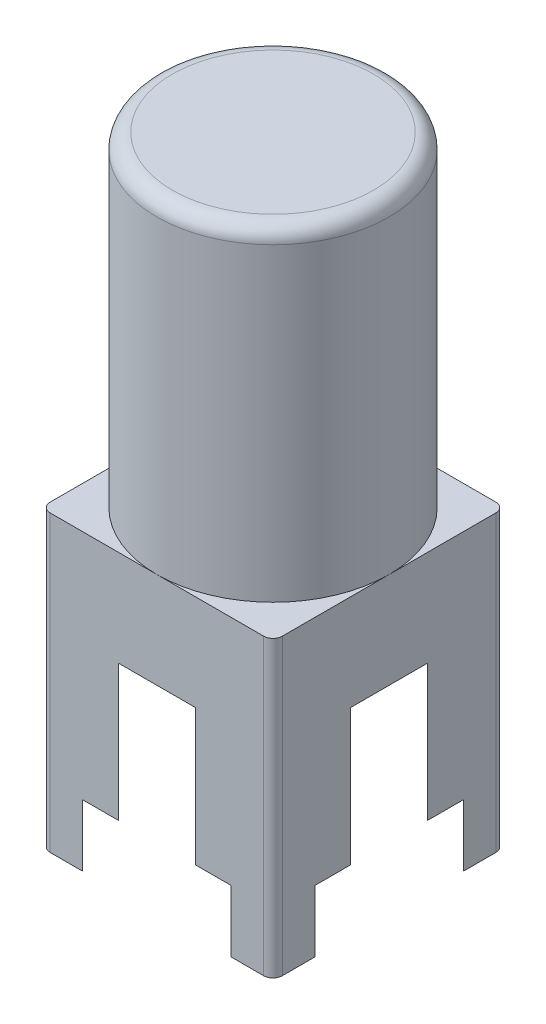
from build123d import *

# Parameters (mm, degrees)
SKETCH1_W           = 9.525
SKETCH1_H           = 9.525
BOSS_EXTRUDE1_DEPTH = 12.065
SKETCH2_R           = 4.7625
BOSS_EXTRUDE2_DEPTH = 13.335
FILLET1_R           = 0.635
SKETCH3_R           = 5.6515
CUT_EXTRUDE1_DEPTH  = 2.54
SKETCH4_R           = 5.0165
CUT_EXTRUDE2_DEPTH  = 5.588
SKETCH5_R           = 3.81
BOSS_EXTRUDE3_DEPTH = 1.27
FILLET2_R           = 0.635
SKETCH6_R           = 0.889
BOSS_EXTRUDE4_DEPTH = 8.128
FILLET4_R           = 0.381


with BuildPart() as part:
    # Sketch1 → Boss-Extrude1 (new body)
    with BuildSketch(Plane(origin=(0, 0, 0), x_dir=(1, 0, 0), z_dir=(0, 1, 0))):
        Rectangle(SKETCH1_W, SKETCH1_H)
    extrude(amount=-BOSS_EXTRUDE1_DEPTH)

    # Sketch2 → Boss-Extrude2 (add)
    with BuildSketch(Plane(origin=(0, 0, 0), x_dir=(1, 0, 0), z_dir=(0, 1, 0))):
        Circle(SKETCH2_R)
    extrude(amount=BOSS_EXTRUDE2_DEPTH)

    # Fillet1
    fillet1_edges = [part.edges().sort_by_distance(p)[0] for p in [
        (-4.7625, 13.335, 0),
    ]]
    fillet(fillet1_edges, radius=FILLET1_R)

    # Sketch3 → Cut-Extrude1 (cut)
    with BuildSketch(Plane.XZ.offset(12.065)):
        Circle(SKETCH3_R)
    extrude(amount=-CUT_EXTRUDE1_DEPTH, mode=Mode.SUBTRACT)

    # Sketch4 → Cut-Extrude2 (cut)
    with BuildSketch(Plane.XZ.offset(9.525)):
        Circle(SKETCH4_R)
    extrude(amount=-CUT_EXTRUDE2_DEPTH, mode=Mode.SUBTRACT)

    # Sketch5 → Boss-Extrude3 (add)
    with BuildSketch(Plane.XZ.offset(3.937)):
        Circle(SKETCH5_R)
    extrude(amount=BOSS_EXTRUDE3_DEPTH)

    # Fillet2
    fillet2_edges = [part.edges().sort_by_distance(p)[0] for p in [
        (-3.81, -5.207, 0),
    ]]
    fillet(fillet2_edges, radius=FILLET2_R)

    # Sketch6 → Boss-Extrude4 (add)
    with BuildSketch(Plane.XZ.offset(3.937)):
        Circle(SKETCH6_R)
    extrude(amount=BOSS_EXTRUDE4_DEPTH)

    # Fillet4
    fillet4_edges = [part.edges().sort_by_distance(p)[0] for p in [
        (4.7625, -6.0325, 4.7625),
        (-4.7625, -6.0325, 4.7625),
        (-4.7625, -6.0325, -4.7625),
        (4.7625, -6.0325, -4.7625),
    ]]
    fillet(fillet4_edges, radius=FILLET4_R)


solid = part.part
